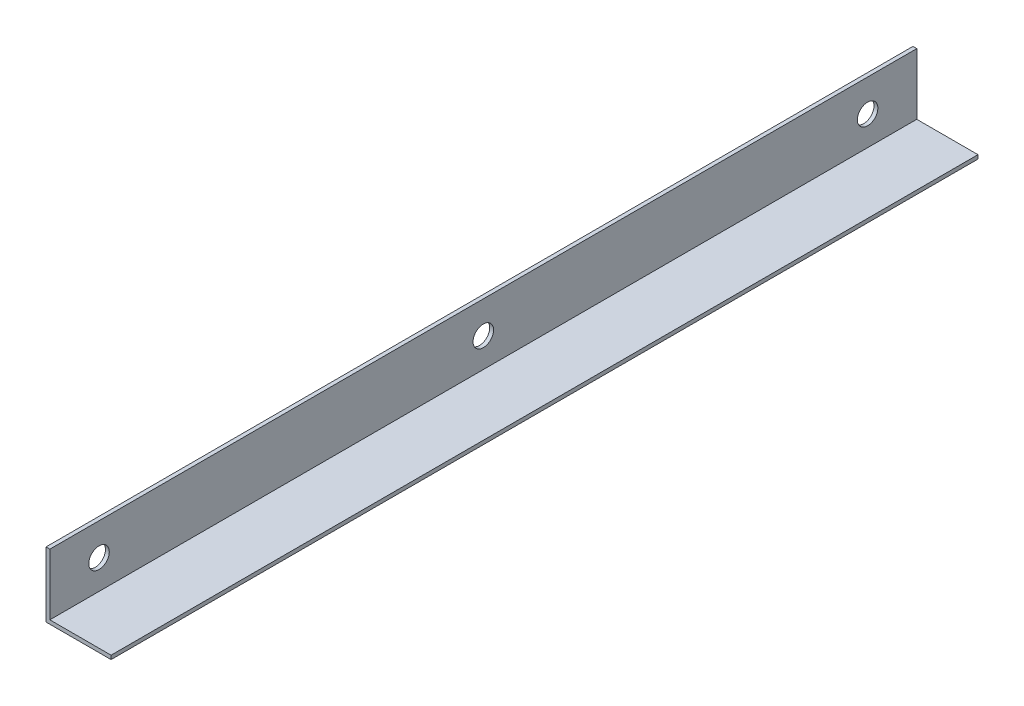
from build123d import *

# Parameters (mm, degrees)
SALIENTE_EXTRUIR1_DEPTH = 338.4
CROQUIS2_R              = 4
CORTAR_EXTRUIR1_DEPTH   = 2


with BuildPart() as part:
    # Croquis1 → Saliente-Extruir1 (new body)
    with BuildSketch(Plane.XY):
        Polygon((0, 0), (0, 25.4), (1.5, 25.4), (1.5, 1.5), (25.4, 1.5), (25.4, 0), align=None)
    extrude(amount=SALIENTE_EXTRUIR1_DEPTH)

    # Croquis2 → Cortar-Extruir1 (cut)
    with BuildSketch(Plane(origin=(1.5, 0, 0), x_dir=(0, 0, -1), z_dir=(1, 0, 0))):
        with Locations((-19.2, 12.9)):
            Circle(CROQUIS2_R)
        with Locations((-319.2, 12.9)):
            Circle(CROQUIS2_R)
        with Locations((-169.2, 12.9)):
            Circle(CROQUIS2_R)
    extrude(amount=-CORTAR_EXTRUIR1_DEPTH, mode=Mode.SUBTRACT)


solid = part.part
